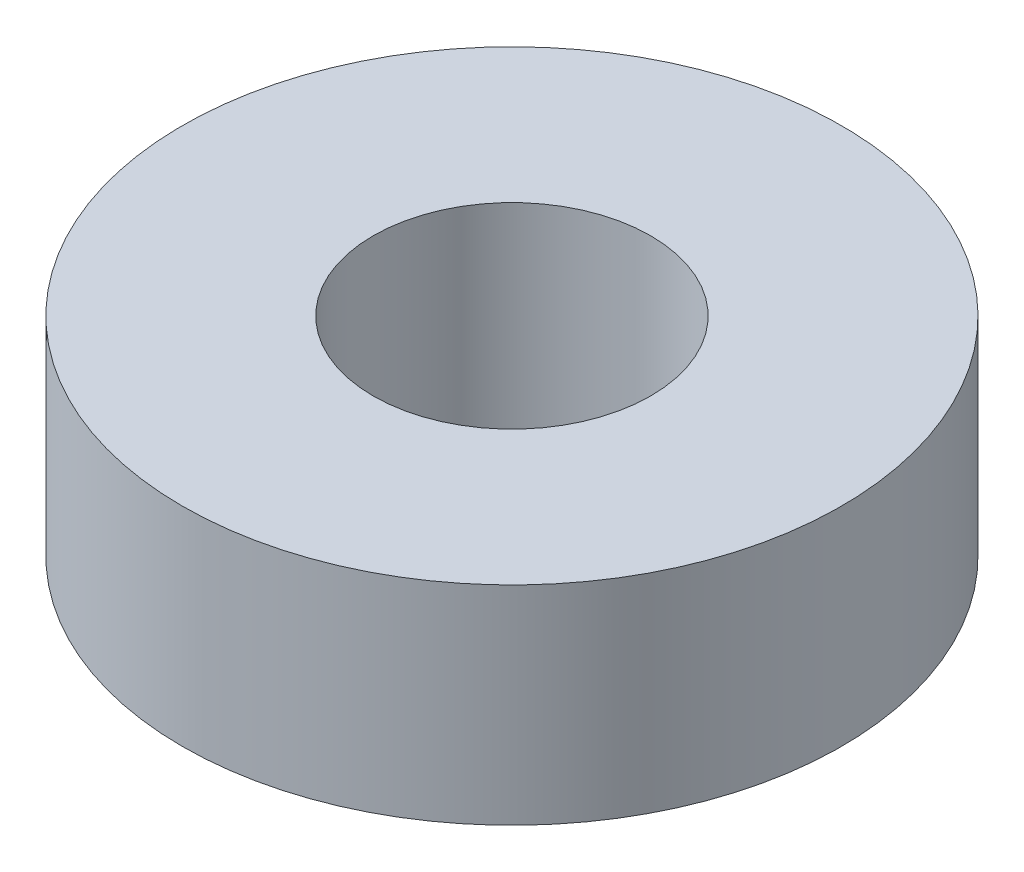
from build123d import *

# Parameters (mm, degrees)
SKETCH1_R           = 9.5
SKETCH1_R_2         = 4
BOSS_EXTRUDE1_DEPTH = 6


with BuildPart() as part:
    # Sketch1 → Boss-Extrude1 (new body)
    with BuildSketch(Plane(origin=(0, 0, 0), x_dir=(1, 0, 0), z_dir=(0, 1, 0))):
        Circle(SKETCH1_R)
        Circle(SKETCH1_R_2, mode=Mode.SUBTRACT)
    extrude(amount=BOSS_EXTRUDE1_DEPTH)


solid = part.part
